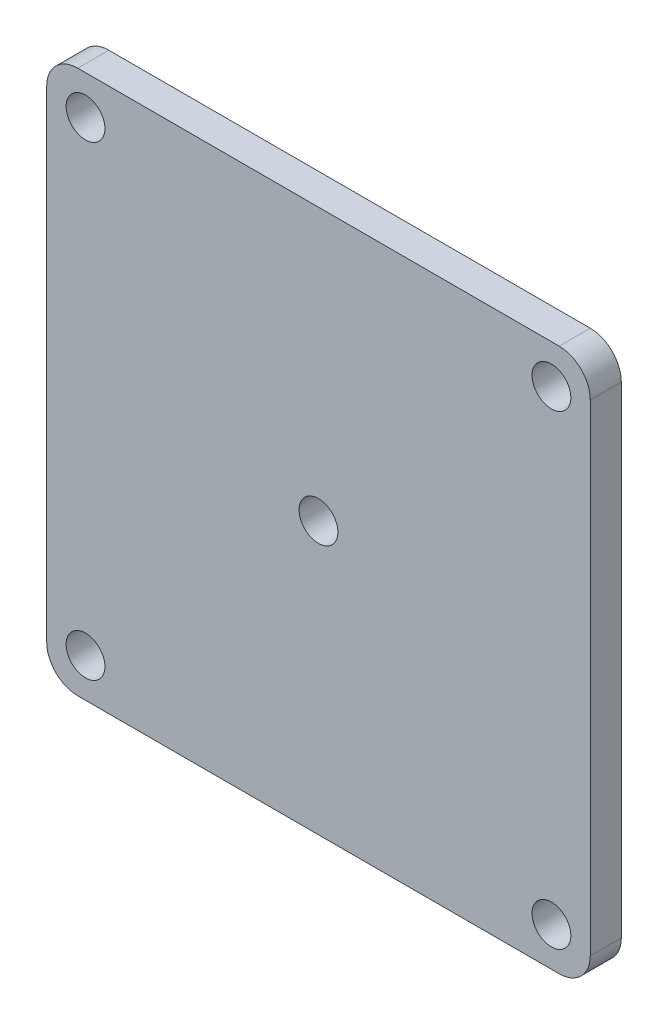
from build123d import *

# Parameters (mm, degrees)
SKETCH1_W           = 88.9
SKETCH1_H           = 88.9
BOSS_EXTRUDE1_DEPTH = 2.54
SKETCH2_R           = 3.175
CUT_EXTRUDE1_DEPTH  = 6.08
FILLET1_R           = 5.08


with BuildPart() as part:
    # Sketch1 → Boss-Extrude1 (new body, symmetric)
    with BuildSketch(Plane.XY):
        with Locations((44.45, 44.45)):
            Rectangle(SKETCH1_W, SKETCH1_H)
    extrude(amount=BOSS_EXTRUDE1_DEPTH, both=True)

    # Sketch2 → Cut-Extrude1 (cut, through all)
    with BuildSketch(Plane.XY.offset(2.54)):
        with Locations((6.35, 82.55)):
            Circle(SKETCH2_R)
        with Locations((82.55, 82.55)):
            Circle(SKETCH2_R)
        with Locations((82.55, 6.35)):
            Circle(SKETCH2_R)
        with Locations((6.35, 6.35)):
            Circle(SKETCH2_R)
        with Locations((44.45, 44.45)):
            Circle(SKETCH2_R)
    extrude(amount=-CUT_EXTRUDE1_DEPTH, mode=Mode.SUBTRACT)

    # Fillet1
    fillet1_edges = [part.edges().sort_by_distance(p)[0] for p in [
        (0, 88.9, 0),
        (88.9, 88.9, 0),
        (88.9, 0, 0),
        (0, 0, 0),
    ]]
    fillet(fillet1_edges, radius=FILLET1_R)


solid = part.part
